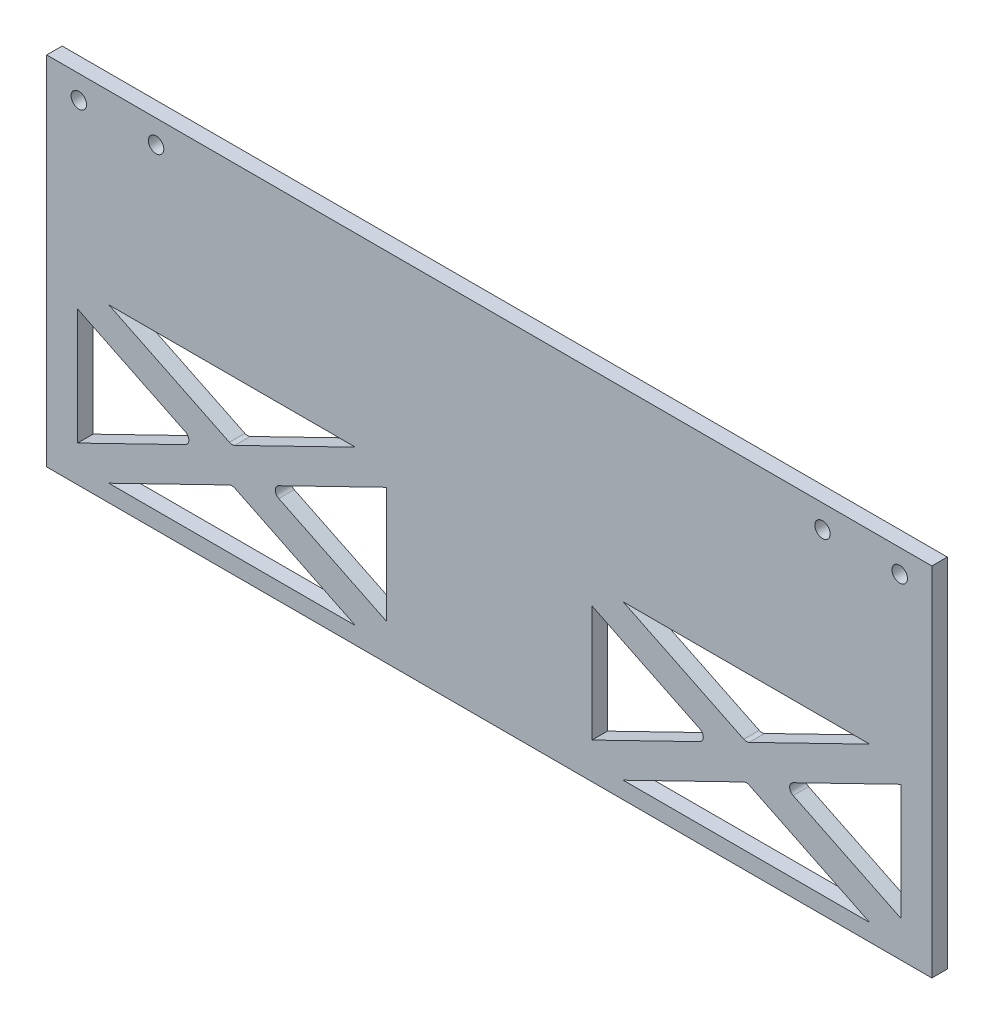
from build123d import *

# Parameters (mm, degrees)
SKETCH6_W           = 286.5
SKETCH6_H           = 180
BOSS_EXTRUDE3_DEPTH = 5
SKETCH7_R           = 2.5
CUT_EXTRUDE1_DEPTH  = 13
SKETCH8_W           = 286.5
SKETCH8_H           = 64.5
CUT_EXTRUDE2_DEPTH  = 6


with BuildPart() as part:
    # Sketch6 → Boss-Extrude3 (new body)
    with BuildSketch(Plane.XY):
        with Locations((0, 90)):
            Rectangle(SKETCH6_W, SKETCH6_H)
    extrude(amount=BOSS_EXTRUDE3_DEPTH)

    # Sketch7 → Cut-Extrude1 (cut)
    with BuildSketch(Plane.XY.offset(5)):
        with Locations((-132.85, 172.5)):
            Circle(SKETCH7_R)
        with Locations((-107.85, 172.5)):
            Circle(SKETCH7_R)
        with BuildLine():
            Line((-82.374047462, 100.988572935), (-43.351346631, 120))
            Line((-43.351346631, 120), (-123.148653369, 120))
            Line((-123.148653369, 120), (-84.125952538, 100.988572935))
            ThreePointArc((-84.125952538, 100.988572935), (-83.25, 100.786546002), (-82.374047462, 100.988572935))
        make_face()
        with BuildLine():
            Line((-133.25, 113.797626904), (-133.25, 76.202373096))
            Line((-133.25, 76.202373096), (-98.356648563, 93.202026933))
            ThreePointArc((-98.356648563, 93.202026933), (-97.232601102, 95), (-98.356648563, 96.797973067))
            Line((-98.356648563, 96.797973067), (-133.25, 113.797626904))
        make_face()
        with BuildLine():
            Line((-68.143351437, 93.202026933), (-33.25, 76.202373096))
            Line((-33.25, 76.202373096), (-33.25, 113.797626904))
            Line((-33.25, 113.797626904), (-68.143351437, 96.797973067))
            ThreePointArc((-68.143351437, 96.797973067), (-69.267398898, 95), (-68.143351437, 93.202026933))
        make_face()
        with BuildLine():
            Line((-43.351346631, 70), (-82.374047462, 89.011427065))
            ThreePointArc((-82.374047462, 89.011427065), (-83.25, 89.213453998), (-84.125952538, 89.011427065))
            Line((-84.125952538, 89.011427065), (-123.148653369, 70))
            Line((-123.148653369, 70), (-43.351346631, 70))
        make_face()
        with BuildLine():
            Line((-43.351346631, 60), (-123.148653369, 60))
            Line((-123.148653369, 60), (-84.125952538, 40.988572935))
            ThreePointArc((-84.125952538, 40.988572935), (-83.25, 40.786546002), (-82.374047462, 40.988572935))
            Line((-82.374047462, 40.988572935), (-43.351346631, 60))
        make_face()
        with BuildLine():
            Line((-98.356648563, 36.797973067), (-133.25, 53.797626904))
            Line((-133.25, 53.797626904), (-133.25, 16.202373096))
            Line((-133.25, 16.202373096), (-98.356648563, 33.202026933))
            ThreePointArc((-98.356648563, 33.202026933), (-97.232601102, 35), (-98.356648563, 36.797973067))
        make_face()
        with BuildLine():
            Line((-33.25, 16.202373096), (-33.25, 53.797626904))
            Line((-33.25, 53.797626904), (-68.143351437, 36.797973067))
            ThreePointArc((-68.143351437, 36.797973067), (-69.267398898, 35), (-68.143351437, 33.202026933))
            Line((-68.143351437, 33.202026933), (-33.25, 16.202373096))
        make_face()
        with BuildLine():
            Line((-84.125952538, 29.011427065), (-123.148653369, 10))
            Line((-123.148653369, 10), (-43.351346631, 10))
            Line((-43.351346631, 10), (-82.374047462, 29.011427065))
            ThreePointArc((-82.374047462, 29.011427065), (-83.25, 29.213453998), (-84.125952538, 29.011427065))
        make_face()
        with BuildLine():
            Line((84.125952538, 100.988572935), (123.148653369, 120))
            Line((123.148653369, 120), (43.351346631, 120))
            Line((43.351346631, 120), (82.374047462, 100.988572935))
            ThreePointArc((82.374047462, 100.988572935), (83.25, 100.786546002), (84.125952538, 100.988572935))
        make_face()
        with BuildLine():
            Line((33.25, 113.797626904), (33.25, 76.202373096))
            Line((33.25, 76.202373096), (68.143351437, 93.202026933))
            ThreePointArc((68.143351437, 93.202026933), (69.267398898, 95), (68.143351437, 96.797973067))
            Line((68.143351437, 96.797973067), (33.25, 113.797626904))
        make_face()
        with BuildLine():
            Line((98.356648563, 93.202026933), (133.25, 76.202373096))
            Line((133.25, 76.202373096), (133.25, 113.797626904))
            Line((133.25, 113.797626904), (98.356648563, 96.797973067))
            ThreePointArc((98.356648563, 96.797973067), (97.232601102, 95), (98.356648563, 93.202026933))
        make_face()
        with BuildLine():
            Line((43.351346631, 70), (123.148653369, 70))
            Line((123.148653369, 70), (84.125952538, 89.011427065))
            ThreePointArc((84.125952538, 89.011427065), (83.25, 89.213453998), (82.374047462, 89.011427065))
            Line((82.374047462, 89.011427065), (43.351346631, 70))
        make_face()
        with BuildLine():
            Line((43.351346631, 60), (82.374047462, 40.988572935))
            ThreePointArc((82.374047462, 40.988572935), (83.25, 40.786546002), (84.125952538, 40.988572935))
            Line((84.125952538, 40.988572935), (123.148653369, 60))
            Line((123.148653369, 60), (43.351346631, 60))
        make_face()
        with BuildLine():
            Line((68.143351437, 36.797973067), (33.25, 53.797626904))
            Line((33.25, 53.797626904), (33.25, 16.202373096))
            Line((33.25, 16.202373096), (68.143351437, 33.202026933))
            ThreePointArc((68.143351437, 33.202026933), (69.267398898, 35), (68.143351437, 36.797973067))
        make_face()
        with BuildLine():
            Line((133.25, 16.202373096), (133.25, 53.797626904))
            Line((133.25, 53.797626904), (98.356648563, 36.797973067))
            ThreePointArc((98.356648563, 36.797973067), (97.232601102, 35), (98.356648563, 33.202026933))
            Line((98.356648563, 33.202026933), (133.25, 16.202373096))
        make_face()
        with BuildLine():
            Line((82.374047462, 29.011427065), (43.351346631, 10))
            Line((43.351346631, 10), (123.148653369, 10))
            Line((123.148653369, 10), (84.125952538, 29.011427065))
            ThreePointArc((84.125952538, 29.011427065), (83.25, 29.213453998), (82.374047462, 29.011427065))
        make_face()
        with Locations((107.85, 172.5)):
            Circle(SKETCH7_R)
        with Locations((132.85, 172.5)):
            Circle(SKETCH7_R)
    extrude(amount=-CUT_EXTRUDE1_DEPTH, mode=Mode.SUBTRACT)

    # Sketch8 → Cut-Extrude2 (cut, through all)
    with BuildSketch(Plane.XY.offset(5)):
        with Locations((0, 32.25)):
            Rectangle(SKETCH8_W, SKETCH8_H)
    extrude(amount=-CUT_EXTRUDE2_DEPTH, mode=Mode.SUBTRACT)


solid = part.part
